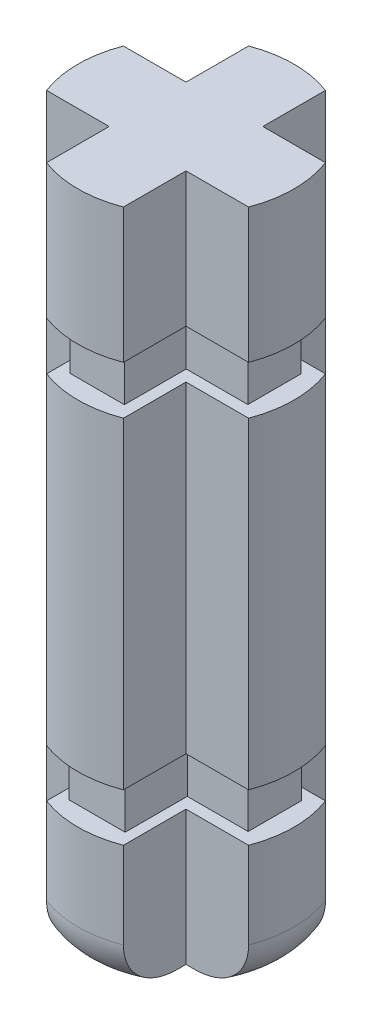
from build123d import *

# Parameters (mm, degrees)
BOSS_EXTRUDE1_DEPTH = 2.8
FILLET1_R           = 1
FILLET2_R           = 1
FILLET3_R           = 1
FILLET4_R           = 1
BOSS_EXTRUDE2_DEPTH = 1
BOSS_EXTRUDE3_DEPTH = 6.7
BOSS_EXTRUDE4_DEPTH = 1
BOSS_EXTRUDE5_DEPTH = 2.8


with BuildPart() as part:
    # Sketch1 → Boss-Extrude1 (new body)
    with BuildSketch(Plane(origin=(0, 0, 0), x_dir=(1, 0, 0), z_dir=(0, 1, 0))):
        with BuildLine():
            Line((-0.8, -0.8), (-0.8, -2.102974084))
            ThreePointArc((-0.8, -2.102974084), (0, -2.25), (0.8, -2.102974084))
            Line((0.8, -2.102974084), (0.8, -0.8))
            Line((0.8, -0.8), (2.102974084, -0.8))
            ThreePointArc((2.102974084, -0.8), (2.25, 0), (2.102974084, 0.8))
            Line((2.102974084, 0.8), (0.8, 0.8))
            Line((0.8, 0.8), (0.8, 2.102974084))
            ThreePointArc((0.8, 2.102974084), (0, 2.25), (-0.8, 2.102974084))
            Line((-0.8, 2.102974084), (-0.8, 0.8))
            Line((-0.8, 0.8), (-2.102974084, 0.8))
            ThreePointArc((-2.102974084, 0.8), (-2.25, 0), (-2.102974084, -0.8))
            Line((-2.102974084, -0.8), (-0.8, -0.8))
        make_face()
    extrude(amount=BOSS_EXTRUDE1_DEPTH)

    # Fillet1
    fillet1_edges = [part.edges().sort_by_distance(p)[0] for p in [
        (-2.25, 0, 0),
    ]]
    fillet(fillet1_edges, radius=FILLET1_R)

    # Fillet2
    fillet2_edges = [part.edges().sort_by_distance(p)[0] for p in [
        (0, 0, 2.25),
    ]]
    fillet(fillet2_edges, radius=FILLET2_R)

    # Fillet3
    fillet3_edges = [part.edges().sort_by_distance(p)[0] for p in [
        (2.25, 0, 0),
    ]]
    fillet(fillet3_edges, radius=FILLET3_R)

    # Fillet4
    fillet4_edges = [part.edges().sort_by_distance(p)[0] for p in [
        (0, 0, -2.25),
    ]]
    fillet(fillet4_edges, radius=FILLET4_R)

    # Sketch3 → Boss-Extrude2 (add)
    with BuildSketch(Plane(origin=(0, 2.8, 0), x_dir=(1, 0, 0), z_dir=(0, 1, 0))):
        Polygon((-0.583389757, 0.556274706), (-0.583389757, 1.85), (0.583389757, 1.85), (0.583389757, 0.556274706), (1.85, 0.556274706), (1.85, -0.556274706), (0.583389757, -0.556274706), (0.583389757, -1.85), (-0.583389757, -1.85), (-0.583389757, -0.556274706), (-1.85, -0.556274706), (-1.85, 0.556274706), align=None)
    extrude(amount=BOSS_EXTRUDE2_DEPTH)

    # Sketch11 → Boss-Extrude3 (add)
    with BuildSketch(Plane(origin=(0, 3.8, 0), x_dir=(1, 0, 0), z_dir=(0, 1, 0))):
        with BuildLine():
            Line((-0.799009338, -0.800292793), (-0.799009338, -2.103266877))
            ThreePointArc((-0.799009338, -2.103266877), (0.000990662, -2.250292793), (0.800990662, -2.103266877))
            Line((0.800990662, -2.103266877), (0.800990662, -0.800292793))
            Line((0.800990662, -0.800292793), (2.103964747, -0.800292793))
            ThreePointArc((2.103964747, -0.800292793), (2.250990662, -0.000292793), (2.103964747, 0.799707207))
            Line((2.103964747, 0.799707207), (0.800990662, 0.799707207))
            Line((0.800990662, 0.799707207), (0.800990662, 2.102681291))
            ThreePointArc((0.800990662, 2.102681291), (0.000990662, 2.249707207), (-0.799009338, 2.102681291))
            Line((-0.799009338, 2.102681291), (-0.799009338, 0.799707207))
            Line((-0.799009338, 0.799707207), (-2.101983422, 0.799707207))
            ThreePointArc((-2.101983422, 0.799707207), (-2.249009338, -0.000292793), (-2.101983422, -0.800292793))
            Line((-2.101983422, -0.800292793), (-0.799009338, -0.800292793))
        make_face()
    extrude(amount=BOSS_EXTRUDE3_DEPTH)

    # Sketch12 → Boss-Extrude4 (add)
    with BuildSketch(Plane(origin=(0, 10.5, 0), x_dir=(1, 0, 0), z_dir=(0, 1, 0))):
        Polygon((0.567460326, 0.546772752), (1.85, 0.546772752), (1.85, -0.562668947), (0.567460326, -0.562668947), (0.567460326, -1.850285006), (-0.565476617, -1.850285006), (-0.565476617, -0.562668947), (-1.85, -0.562668947), (-1.85, 0.546772752), (-0.565476617, 0.546772752), (-0.565476617, 1.849714994), (0.567460326, 1.849714994), align=None)
    extrude(amount=BOSS_EXTRUDE4_DEPTH)

    # Sketch13 → Boss-Extrude5 (add)
    with BuildSketch(Plane(origin=(0, 11.5, 0), x_dir=(1, 0, 0), z_dir=(0, 1, 0))):
        with BuildLine():
            Line((-0.806071321, -0.793579744), (-0.806071321, -2.096553829))
            ThreePointArc((-0.806071321, -2.096553829), (-0.006071321, -2.243579744), (0.793928679, -2.096553829))
            Line((0.793928679, -2.096553829), (0.793928679, -0.793579744))
            Line((0.793928679, -0.793579744), (2.096902763, -0.793579744))
            ThreePointArc((2.096902763, -0.793579744), (2.243928679, 0.006420256), (2.096902763, 0.806420256))
            Line((2.096902763, 0.806420256), (0.793928679, 0.806420256))
            Line((0.793928679, 0.806420256), (0.793928679, 2.10939434))
            ThreePointArc((0.793928679, 2.10939434), (-0.006071321, 2.256420256), (-0.806071321, 2.10939434))
            Line((-0.806071321, 2.10939434), (-0.806071321, 0.806420256))
            Line((-0.806071321, 0.806420256), (-2.109045406, 0.806420256))
            ThreePointArc((-2.109045406, 0.806420256), (-2.256071321, 0.006420256), (-2.109045406, -0.793579744))
            Line((-2.109045406, -0.793579744), (-0.806071321, -0.793579744))
        make_face()
    extrude(amount=BOSS_EXTRUDE5_DEPTH)


solid = part.part
